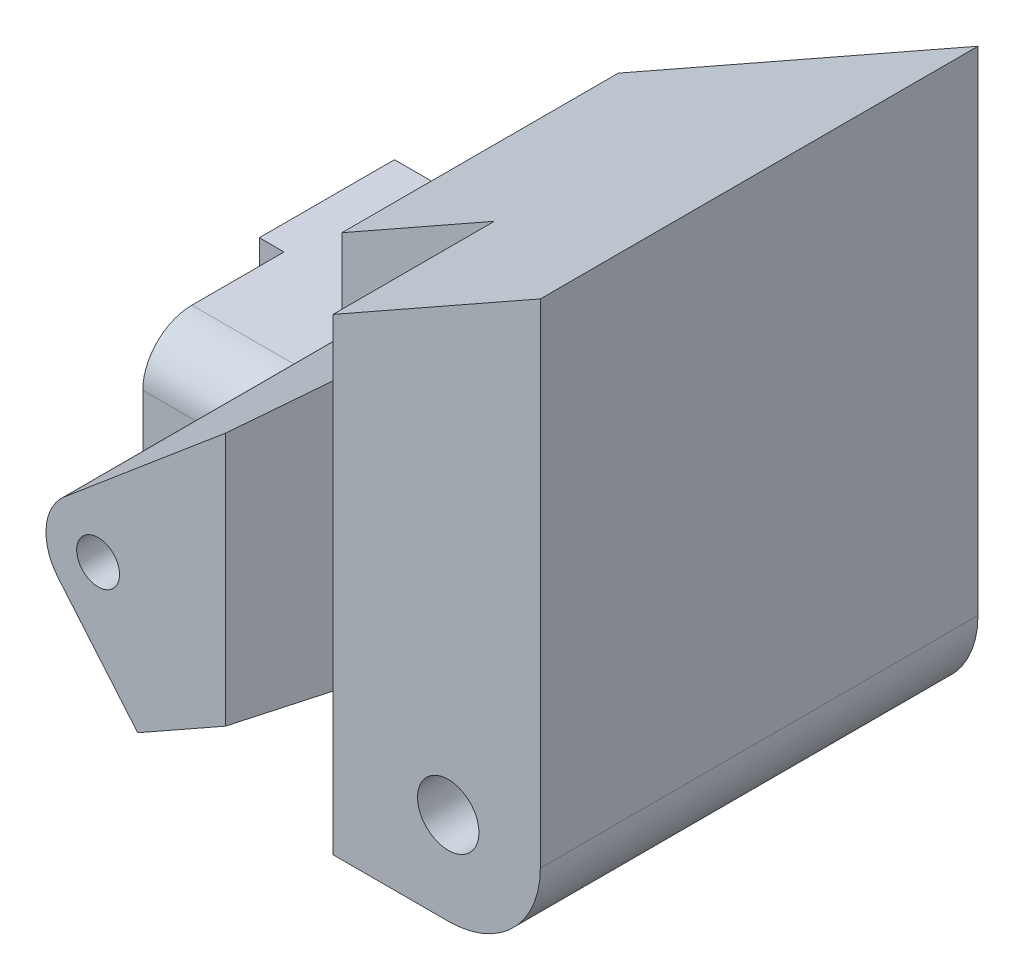
from build123d import *

# Parameters (mm, degrees)
SKETCH8_R           = 2
BOSS_EXTRUDE6_DEPTH = 9
BOSS_EXTRUDE7_START = -9
SKETCH9_R           = 1.395
BOSS_EXTRUDE7_DEPTH = 32
CHAMFER3_SIZE       = 3.5
BOSS_EXTRUDE8_START = -9
SKETCH11_R          = 2
BOSS_EXTRUDE8_DEPTH = 28.5
CUT_EXTRUDE1_START  = -0.2
CUT_EXTRUDE1_DEPTH  = 24.2
FILLET5_R           = 3.2


with BuildPart() as part:
    # Sketch8 → Boss-Extrude6 (new body, symmetric)
    with BuildSketch(Plane.XY):
        with BuildLine():
            Line((-16, -16.195281799), (-16, -22.05))
            Line((-16, -22.05), (16, -22.05))
            ThreePointArc((16, -22.05), (20.242640687, -20.292640687), (22, -16.05))
            Line((22, -16.05), (22, 16.05))
            Line((22, 16.05), (-1.424393869, 2.820825363))
            Line((-1.424393869, 2.820825363), (-1.424393869, -9.35))
            Line((-1.424393869, -9.35), (-1.949620424, -9.35))
            ThreePointArc((-1.949620424, -9.35), (-3.3, -11.095), (-4.650379576, -9.35))
            Line((-4.650379576, -9.35), (-16, -9.35))
            Line((-16, -9.35), (-16, -16.195281799))
        make_face()
        with Locations((16, -16.05)):
            Circle(SKETCH8_R, mode=Mode.SUBTRACT)
    extrude(amount=BOSS_EXTRUDE6_DEPTH, both=True)

    # Sketch9 → Boss-Extrude7 (add)
    with BuildSketch(Plane.XY.offset(BOSS_EXTRUDE7_START)):
        with BuildLine():
            Line((8.5, 4.678478311), (-5.487189769, -7.103420343))
            ThreePointArc((-5.487189769, -7.103420343), (-6.682635801, -9.410517634), (-5.896579657, -11.887189769))
            Line((-5.896579657, -11.887189769), (-0.72278451, -18.029396273))
            Line((-0.72278451, -18.029396273), (8.5, -12.820730998))
            Line((8.5, -12.820730998), (8.5, 4.678478311))
        make_face()
        with Locations((-3.3, -9.7)):
            Circle(SKETCH9_R, mode=Mode.SUBTRACT)
    extrude(amount=BOSS_EXTRUDE7_DEPTH)

    # Chamfer3
    chamfer3_edges = [part.edges().sort_by_distance(p)[0] for p in [
        (8.5, -4.071126344, 23),
    ]]
    chamfer(chamfer3_edges, length=CHAMFER3_SIZE)

    # Sketch11 → Boss-Extrude8 (add)
    with BuildSketch(Plane.XY.offset(BOSS_EXTRUDE8_START)):
        with BuildLine():
            Line((8.5, 8.425731957), (8.5, -22.05))
            Line((8.5, -22.05), (16, -22.05))
            ThreePointArc((16, -22.05), (20.242640687, -20.292640687), (22, -16.05))
            Line((22, -16.05), (22, 16.05))
            Line((22, 16.05), (8.5, 8.425731957))
        make_face()
        with Locations((16, -16.05)):
            Circle(SKETCH11_R, mode=Mode.SUBTRACT)
    extrude(amount=BOSS_EXTRUDE8_DEPTH)

    # Sketch8_4 → Cut-Extrude1 (cut, through all)
    with BuildSketch(Plane.XY.offset(CUT_EXTRUDE1_START)):
        Polygon((-16, -16.195281799), (-16, -22.05), (-14.391687016, -22.05), (-14.391687016, -9.35), (-16, -9.35), align=None)
    extrude(amount=CUT_EXTRUDE1_DEPTH, mode=Mode.SUBTRACT)

    # Fillet5
    fillet5_edges = [part.edges().sort_by_distance(p)[0] for p in [
        (-10.534298793, -9.35, 9),
        (-2.945843508, -22.05, 9),
    ]]
    fillet(fillet5_edges, radius=FILLET5_R)


solid = part.part
